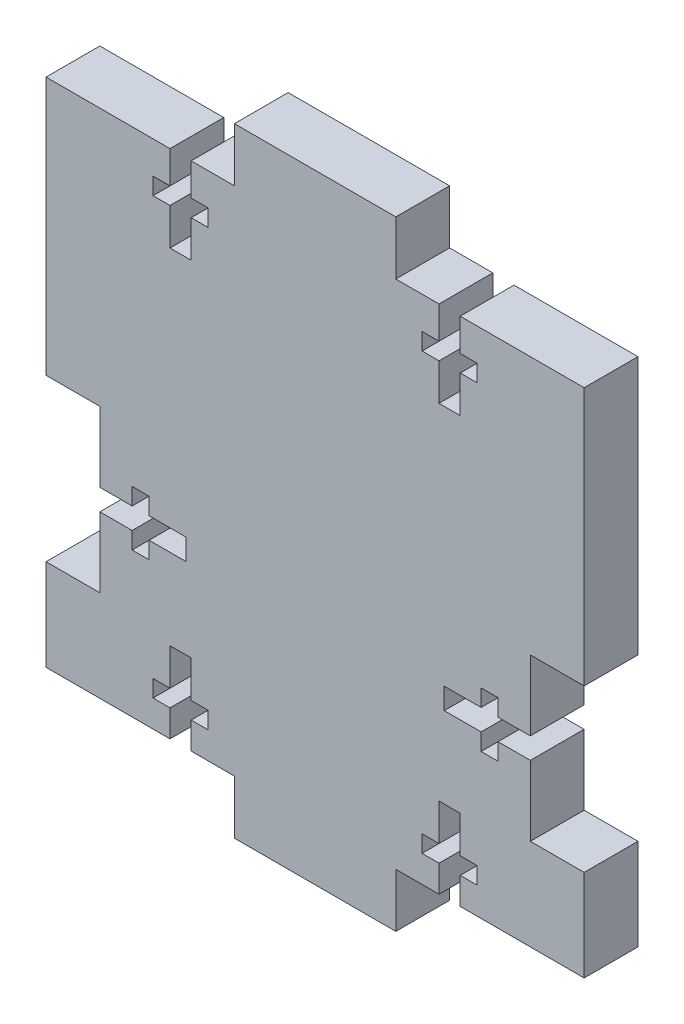
from build123d import *

# Parameters (mm, degrees)
BOSS_EXTRUDE1_DEPTH = 6.35


with BuildPart() as part:
    # Sketch1 → Boss-Extrude1 (new body)
    with BuildSketch(Plane.XY):
        Polygon((0, -6.35), (19.05, -6.35), (19.05, 0), (24.15, 0), (24.15, 3.175), (22.15, 3.175), (22.15, 5.175), (24.15, 5.175), (24.15, 9.525), (26.65, 9.525), (26.65, 5.175), (28.65, 5.175), (28.65, 3.175), (26.65, 3.175), (26.65, 0), (34.925, 0), (41.275, 0), (41.275, 10.795), (34.925, 10.795), (34.925, 19.07), (31.115, 19.07), (31.115, 17.07), (29.115, 17.07), (29.115, 19.07), (24.765, 19.07), (24.765, 21.57), (29.115, 21.57), (29.115, 23.57), (31.115, 23.57), (31.115, 21.57), (34.925, 21.57), (34.925, 29.845), (41.275, 29.845), (41.275, 60.325), (34.925, 60.325), (26.65, 60.325), (26.65, 56.515), (28.65, 56.515), (28.65, 54.515), (26.65, 54.515), (26.65, 50.165), (24.15, 50.165), (24.15, 54.515), (22.15, 54.515), (22.15, 56.515), (24.15, 56.515), (24.15, 60.325), (19.05, 60.325), (19.05, 66.675), (0, 66.675), (0, 60.325), (-5.1, 60.325), (-5.1, 56.515), (-3.1, 56.515), (-3.1, 54.515), (-5.1, 54.515), (-5.1, 50.165), (-7.6, 50.165), (-7.6, 54.515), (-9.6, 54.515), (-9.6, 56.515), (-7.6, 56.515), (-7.6, 60.325), (-15.875, 60.325), (-22.225, 60.325), (-22.225, 29.845), (-15.875, 29.845), (-15.875, 21.57), (-12.065, 21.57), (-12.065, 23.57), (-10.065, 23.57), (-10.065, 21.57), (-5.715, 21.57), (-5.715, 19.07), (-10.065, 19.07), (-10.065, 17.07), (-12.065, 17.07), (-12.065, 19.07), (-15.875, 19.07), (-15.875, 10.795), (-22.225, 10.795), (-22.225, 0), (-15.875, 0), (-7.6, 0), (-7.6, 3.175), (-9.6, 3.175), (-9.6, 5.175), (-7.6, 5.175), (-7.6, 9.525), (-5.1, 9.525), (-5.1, 5.175), (-3.1, 5.175), (-3.1, 3.175), (-5.1, 3.175), (-5.1, 0), (0, 0), align=None)
    extrude(amount=BOSS_EXTRUDE1_DEPTH)


solid = part.part
